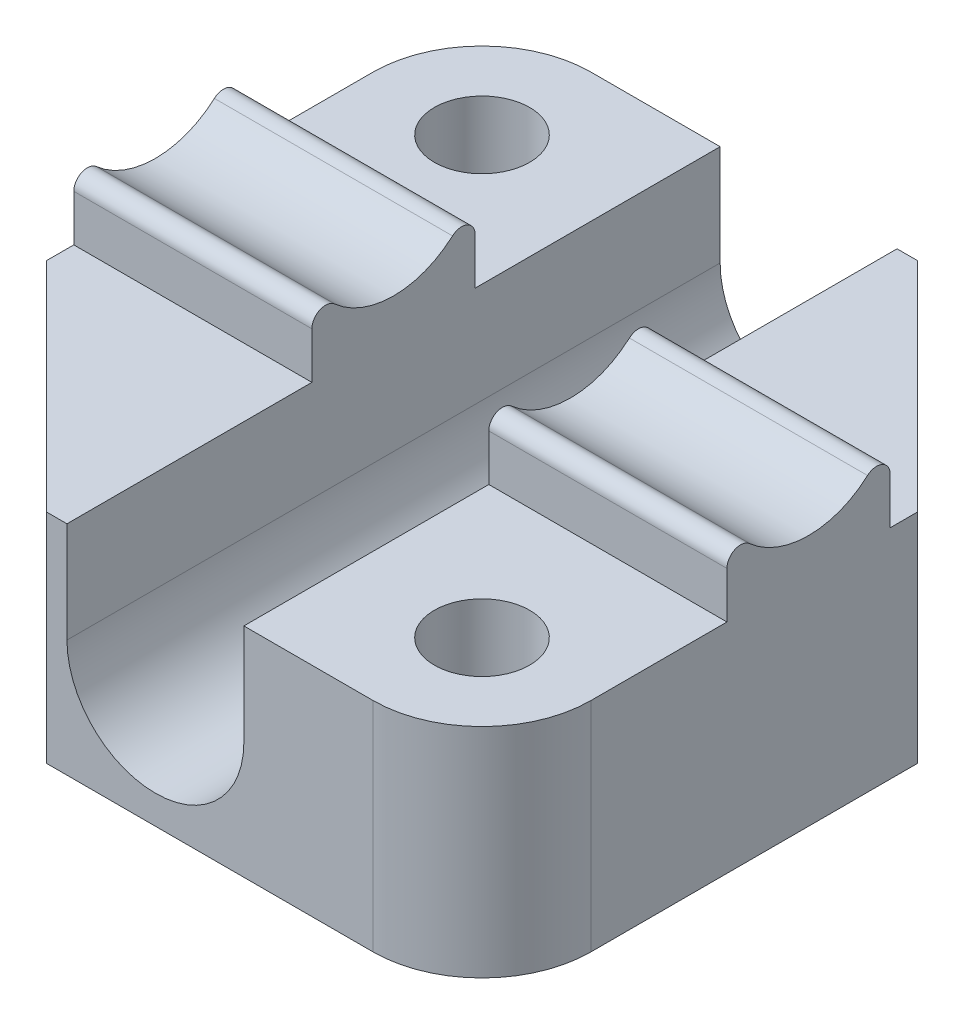
from build123d import *

# Parameters (mm, degrees)
SKETCH_1_W               = 24
SKETCH_1_H               = 24
EXTRUDE_1_DEPTH          = 8
SKETCH_2_R               = 3.25
SKETCH_2_W               = 6.5
SKETCH_2_H               = 3.7
CUT_EXTRUDE_1_DEPTH      = 1
CUT_EXTRUDE_1_DEPTH_BACK = 25
EXTRUDE_2_DEPTH          = 8.75
SKETCH_5_R               = 1.75
CUT_EXTRUDE_3_DEPTH      = 9
CHAMFER_1_SIZE           = 8
FILLET_1_R               = 4
FILLET_2_R               = 0.5
SKETCH_9_R               = 2
CUT_EXTRUDE_4_DEPTH      = 11.204915028
CHAMFER_3_SIZE           = 0.5


with BuildPart() as part:
    # 草图1 → 凸台-拉伸1 (new body)
    with BuildSketch(Plane(origin=(0, 0, 0), x_dir=(1, 0, 0), z_dir=(0, 1, 0))):
        Rectangle(SKETCH_1_W, SKETCH_1_H)
    extrude(amount=EXTRUDE_1_DEPTH)

    # 草图2 → 切除-拉伸1 (cut, two sides)
    with BuildSketch(Plane.XY.offset(12)) as cut_extrude_1_sk:
        with Locations((0, 4.3)):
            Circle(SKETCH_2_R)
        with Locations((0, 6.15)):
            Rectangle(SKETCH_2_W, SKETCH_2_H)
    extrude(amount=CUT_EXTRUDE_1_DEPTH, mode=Mode.SUBTRACT)
    extrude(cut_extrude_1_sk.sketch, amount=-CUT_EXTRUDE_1_DEPTH_BACK, mode=Mode.SUBTRACT)

    # 草图4 → 凸台-拉伸2 (add)
    with BuildSketch(Plane(origin=(12, 0, 0), x_dir=(0, 0, -1), z_dir=(1, 0, 0))):
        with BuildLine():
            Line((-3, 8), (3, 8))
            Line((3, 8), (3, 11.25))
            ThreePointArc((3, 11.25), (0, 9.25), (-3, 11.25))
            Line((-3, 11.25), (-3, 8))
        make_face()
    extrude_2 = extrude(amount=-EXTRUDE_2_DEPTH)

    # 镜向2: 凸台-拉伸2 across plane
    add(extrude_2.mirror(Plane(origin=(0, 0, 0), x_dir=(0, 0, 1), z_dir=(1, 0, 0))))

    # 草图5 → 切除-拉伸3 (cut, through all)
    with BuildSketch(Plane(origin=(0, 8, 0), x_dir=(1, 0, 0), z_dir=(0, 1, 0))):
        with Locations((-8, 8)):
            Circle(SKETCH_5_R)
        with Locations((8, -8)):
            Circle(SKETCH_5_R)
    extrude(amount=-CUT_EXTRUDE_3_DEPTH, mode=Mode.SUBTRACT)

    # 倒角1
    chamfer_1_edges = [part.edges().sort_by_distance(p)[0] for p in [
        (-12, 4, 12),
        (12, 4, -12),
    ]]
    chamfer(chamfer_1_edges, length=CHAMFER_1_SIZE)

    # 圆角1
    fillet_1_edges = [part.edges().sort_by_distance(p)[0] for p in [
        (12, 4, 12),
        (-12, 4, -12),
    ]]
    fillet(fillet_1_edges, radius=FILLET_1_R)

    # 圆角2
    fillet_2_edges = [part.edges().sort_by_distance(p)[0] for p in [
        (7.625, 11.25, 3),
        (7.625, 11.25, -3),
        (-7.625, 11.25, -3),
        (-7.625, 11.25, 3),
    ]]
    fillet(fillet_2_edges, radius=FILLET_2_R)

    # 草图9 → 切除-拉伸4 (cut, through all)
    with BuildSketch(Plane.XZ):
        Circle(SKETCH_9_R)
    extrude(amount=-CUT_EXTRUDE_4_DEPTH, mode=Mode.SUBTRACT)

    # 倒角3
    chamfer_3_edges = [part.edges().sort_by_distance(p)[0] for p in [
        (-9.75, 0, -8),
        (6.25, 0, 8),
    ]]
    chamfer(chamfer_3_edges, length=CHAMFER_3_SIZE)


solid = part.part
